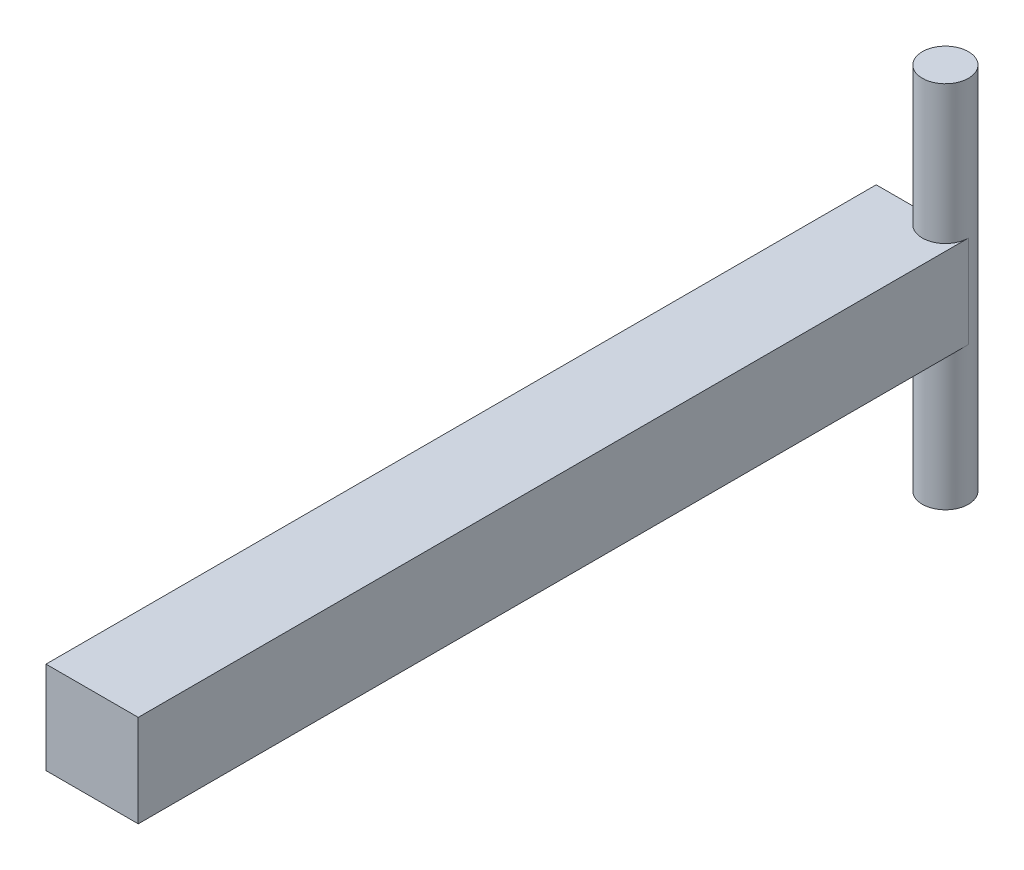
from build123d import *

# Parameters (mm, degrees)
SKETCH_1_W      = 4
SKETCH_1_H      = 4
EXTRUDE_1_DEPTH = 36
SKETCH_3_R      = 1
EXTRUDE_2_DEPTH = 8


with BuildPart() as part:
    # 草图1 → 凸台-拉伸1 (new body)
    with BuildSketch(Plane.XY):
        Rectangle(SKETCH_1_W, SKETCH_1_H)
    extrude(amount=EXTRUDE_1_DEPTH)

    # 草图3 → 凸台-拉伸2 (add, symmetric)
    with BuildSketch(Plane(origin=(0, 0, 0), x_dir=(1, 0, 0), z_dir=(0, 1, 0))):
        with Locations((1, 0)):
            Circle(SKETCH_3_R)
    extrude(amount=EXTRUDE_2_DEPTH, both=True)


solid = part.part
